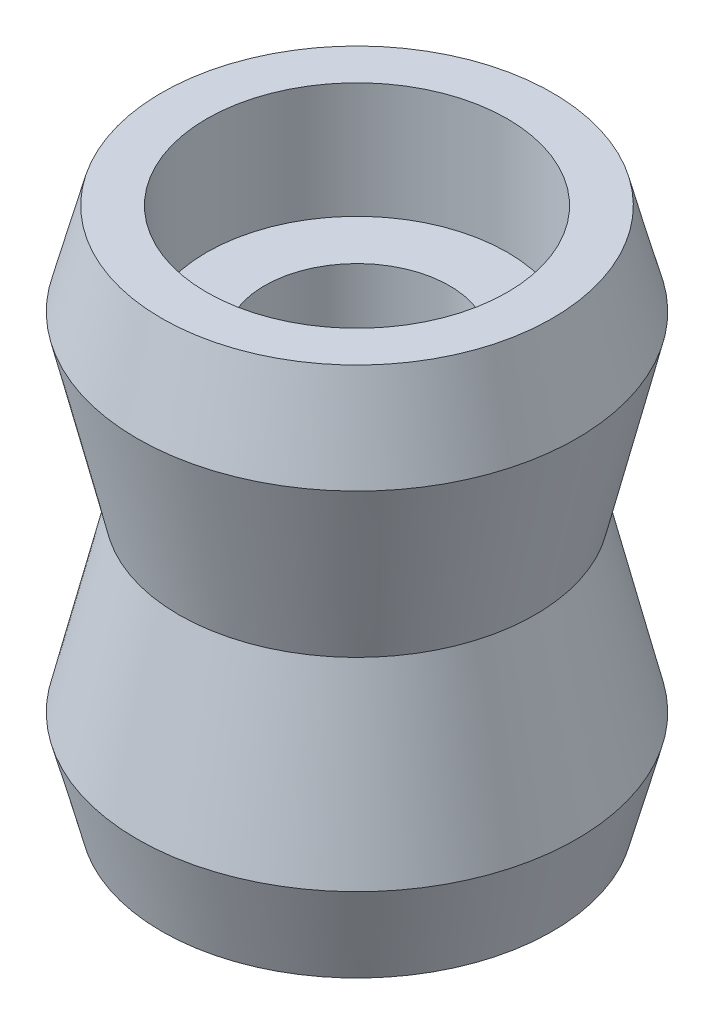
from build123d import *


with BuildPart() as part:
    # Sketch1 → Revolve1 (revolve)
    with BuildSketch(Plane.XY):
        Polygon((4, -3.284366974), (4, 9.669000537), (6.5, 9.669000537), (6.5, 14.669000537), (8.448345124, 14.669000537), (9.5, 10.692316782), (7.7, 3.192316782), (9.5, -4.307683218), (8.448345124, -8.284366974), (6.5, -8.284366974), (6.5, -3.284366974), align=None)
    revolve(axis=Axis((0, 42.323455848, 0), (0, -1, 0)))


solid = part.part
